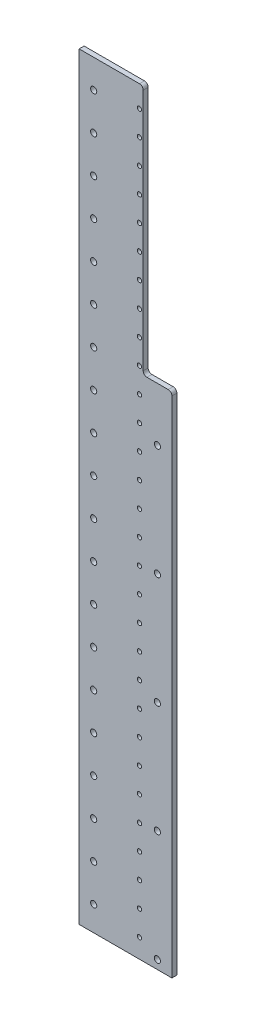
from build123d import *

# Parameters (mm, degrees)
SKETCH_2_W          = 75
SKETCH_2_H          = 613
EXTRUDE_1_DEPTH     = 4
SKETCH_7_W          = 23.197141887
SKETCH_7_H          = 202.515498828
CUT_EXTRUDE_2_DEPTH = 5
FILLET_1_R          = 3
SKETCH_8_R          = 1.75
CUT_EXTRUDE_3_DEPTH = 5
SKETCH_9_R          = 2.5
CUT_EXTRUDE_4_DEPTH = 5
SKETCH_10_R         = 2.5
CUT_EXTRUDE_5_DEPTH = 5


with BuildPart() as part:
    # 草图2 → 凸台-拉伸1 (new body)
    with BuildSketch(Plane.XY):
        with Locations((37.5, -306.5)):
            Rectangle(SKETCH_2_W, SKETCH_2_H)
    extrude(amount=EXTRUDE_1_DEPTH)

    # 草图7 → 切除-拉伸2 (cut, through all)
    with BuildSketch(Plane(origin=(0, 0, 0), x_dir=(-1, 0, 0), z_dir=(0, 0, -1))):
        with Locations((-63.401429057, -101.257749414)):
            Rectangle(SKETCH_7_W, SKETCH_7_H)
    extrude(amount=-CUT_EXTRUDE_2_DEPTH, mode=Mode.SUBTRACT)

    # 圆角1
    fillet_1_edges = [part.edges().sort_by_distance(p)[0] for p in [
        (75, -202.515498828, 2),
        (51.802858113, 0, 2),
        (51.802858113, -202.515498828, 2),
    ]]
    fillet(fillet_1_edges, radius=FILLET_1_R)

    # 草图8 → 切除-拉伸3 (cut, through all)
    with BuildSketch(Plane(origin=(0, 0, 0), x_dir=(-1, 0, 0), z_dir=(0, 0, -1))):
        with Locations((-48.75, -17.5)):
            Circle(SKETCH_8_R)
        with Locations((-48.75, -37.5)):
            Circle(SKETCH_8_R)
        with Locations((-48.75, -57.5)):
            Circle(SKETCH_8_R)
        with Locations((-48.75, -77.5)):
            Circle(SKETCH_8_R)
        with Locations((-48.75, -97.5)):
            Circle(SKETCH_8_R)
        with Locations((-48.75, -117.5)):
            Circle(SKETCH_8_R)
        with Locations((-48.75, -137.5)):
            Circle(SKETCH_8_R)
        with Locations((-48.75, -157.5)):
            Circle(SKETCH_8_R)
        with Locations((-48.75, -177.5)):
            Circle(SKETCH_8_R)
        with Locations((-48.75, -197.5)):
            Circle(SKETCH_8_R)
        with Locations((-48.75, -217.5)):
            Circle(SKETCH_8_R)
        with Locations((-48.75, -237.5)):
            Circle(SKETCH_8_R)
        with Locations((-48.75, -257.5)):
            Circle(SKETCH_8_R)
        with Locations((-48.75, -277.5)):
            Circle(SKETCH_8_R)
        with Locations((-48.75, -297.5)):
            Circle(SKETCH_8_R)
        with Locations((-48.75, -317.5)):
            Circle(SKETCH_8_R)
        with Locations((-48.75, -337.5)):
            Circle(SKETCH_8_R)
        with Locations((-48.75, -357.5)):
            Circle(SKETCH_8_R)
        with Locations((-48.75, -377.5)):
            Circle(SKETCH_8_R)
        with Locations((-48.75, -397.5)):
            Circle(SKETCH_8_R)
        with Locations((-48.75, -417.5)):
            Circle(SKETCH_8_R)
        with Locations((-48.75, -437.5)):
            Circle(SKETCH_8_R)
        with Locations((-48.75, -457.5)):
            Circle(SKETCH_8_R)
        with Locations((-48.75, -477.5)):
            Circle(SKETCH_8_R)
        with Locations((-48.75, -497.5)):
            Circle(SKETCH_8_R)
        with Locations((-48.75, -517.5)):
            Circle(SKETCH_8_R)
        with Locations((-48.75, -537.5)):
            Circle(SKETCH_8_R)
        with Locations((-48.75, -557.5)):
            Circle(SKETCH_8_R)
        with Locations((-48.75, -577.5)):
            Circle(SKETCH_8_R)
        with Locations((-48.75, -597.5)):
            Circle(SKETCH_8_R)
    extrude(amount=-CUT_EXTRUDE_3_DEPTH, mode=Mode.SUBTRACT)

    # 草图9 → 切除-拉伸4 (cut, through all)
    with BuildSketch(Plane.XY.offset(4)):
        with Locations((11.75, -593)):
            Circle(SKETCH_9_R)
        with Locations((11.75, -563)):
            Circle(SKETCH_9_R)
        with Locations((11.75, -533)):
            Circle(SKETCH_9_R)
        with Locations((11.75, -503)):
            Circle(SKETCH_9_R)
        with Locations((11.75, -473)):
            Circle(SKETCH_9_R)
        with Locations((11.75, -443)):
            Circle(SKETCH_9_R)
        with Locations((11.75, -413)):
            Circle(SKETCH_9_R)
        with Locations((11.75, -383)):
            Circle(SKETCH_9_R)
        with Locations((11.75, -353)):
            Circle(SKETCH_9_R)
        with Locations((11.75, -323)):
            Circle(SKETCH_9_R)
        with Locations((11.75, -293)):
            Circle(SKETCH_9_R)
        with Locations((11.75, -263)):
            Circle(SKETCH_9_R)
        with Locations((11.75, -233)):
            Circle(SKETCH_9_R)
        with Locations((11.75, -203)):
            Circle(SKETCH_9_R)
        with Locations((11.75, -173)):
            Circle(SKETCH_9_R)
        with Locations((11.75, -143)):
            Circle(SKETCH_9_R)
        with Locations((11.75, -113)):
            Circle(SKETCH_9_R)
        with Locations((11.75, -83)):
            Circle(SKETCH_9_R)
        with Locations((11.75, -53)):
            Circle(SKETCH_9_R)
        with Locations((11.75, -23)):
            Circle(SKETCH_9_R)
    extrude(amount=-CUT_EXTRUDE_4_DEPTH, mode=Mode.SUBTRACT)

    # 草图10 → 切除-拉伸5 (cut, through all)
    with BuildSketch(Plane.XY.offset(4)):
        with Locations((63.25, -605.950596653)):
            Circle(SKETCH_10_R)
        with Locations((63.25, -515.950596653)):
            Circle(SKETCH_10_R)
        with Locations((63.25, -425.950596653)):
            Circle(SKETCH_10_R)
        with Locations((63.25, -335.950596653)):
            Circle(SKETCH_10_R)
        with Locations((63.25, -245.950596653)):
            Circle(SKETCH_10_R)
    extrude(amount=-CUT_EXTRUDE_5_DEPTH, mode=Mode.SUBTRACT)


solid = part.part
